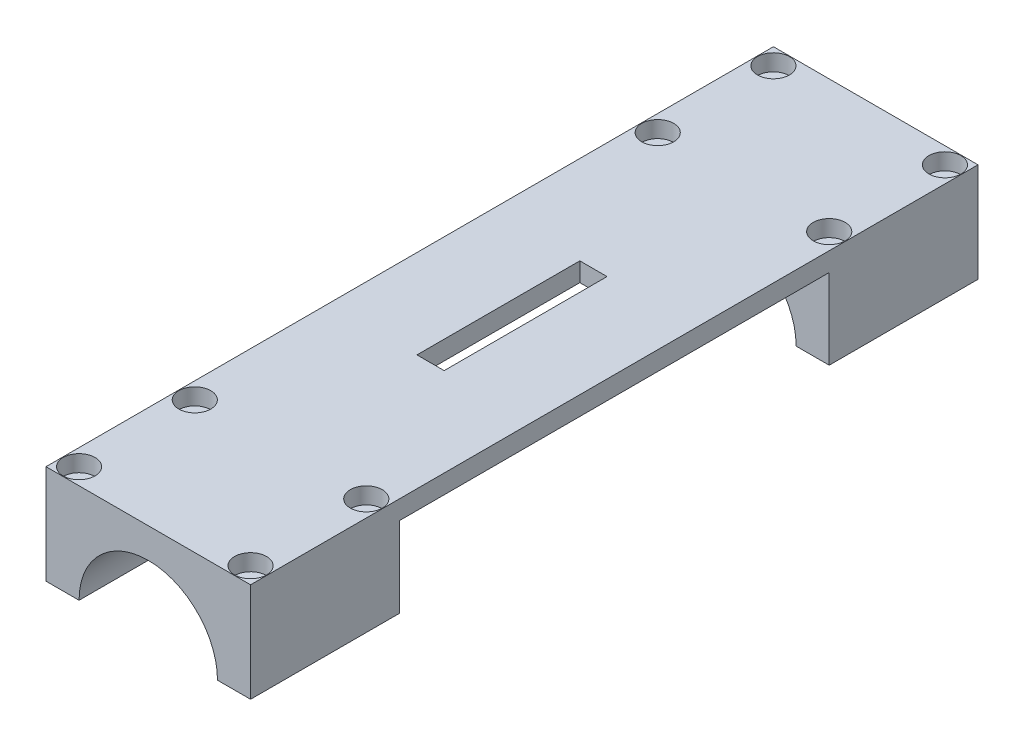
from build123d import *

# Parameters (mm, degrees)
BOSS_EXTRU_1_DEPTH      = 132
ESQUISSE2_W             = 78
ESQUISSE2_H             = 14.57
ENL_V_MAT_EXTRU_1_DEPTH = 132
ESQUISSE3_W             = 4.94012132
ESQUISSE3_H             = 29.556292602
ENL_V_MAT_EXTRU_2_DEPTH = 4
ESQUISSE4_R             = 1.3
ENL_V_MAT_EXTRU_3_DEPTH = 18
ESQUISSE6_R             = 2.9
ENL_V_MAT_EXTRU_5_DEPTH = 3


with BuildPart() as part:
    # Esquisse1 → Boss.-Extru.1 (new body)
    with BuildSketch(Plane.XY):
        with BuildLine():
            Line((-12.560062385, 0), (-18.560062385, 0))
            Line((-18.560062385, 0), (-18.560062385, 18))
            Line((-18.560062385, 18), (18.560062385, 18))
            Line((18.560062385, 18), (18.560062385, 0))
            Line((18.560062385, 0), (12.560062385, 0))
            ThreePointArc((12.560062385, 0), (0, 12.560062385), (-12.560062385, 0))
        make_face()
    extrude(amount=BOSS_EXTRU_1_DEPTH)

    # Esquisse2 → Enlèv. mat.-Extru.1 (cut)
    with BuildSketch(Plane.ZY.offset(18.560062385)):
        with Locations((66, 7.285)):
            Rectangle(ESQUISSE2_W, ESQUISSE2_H)
    extrude(amount=-ENL_V_MAT_EXTRU_1_DEPTH, mode=Mode.SUBTRACT)

    # Esquisse3 → Enlèv. mat.-Extru.2 (cut)
    with BuildSketch(Plane.XZ.offset(-14.57)):
        with Locations((0, 66)):
            Rectangle(ESQUISSE3_W, ESQUISSE3_H)
    extrude(amount=-ENL_V_MAT_EXTRU_2_DEPTH, mode=Mode.SUBTRACT)

    # Esquisse4 → Enlèv. mat.-Extru.3 (cut)
    with BuildSketch(Plane(origin=(0, 18, 0), x_dir=(1, 0, 0), z_dir=(0, 1, 0))):
        with Locations((15.560062385, -3)):
            Circle(ESQUISSE4_R)
        with Locations((15.560062385, -24)):
            Circle(ESQUISSE4_R)
        with Locations((-15.560062385, -3)):
            Circle(ESQUISSE4_R)
        with Locations((-15.560062385, -24)):
            Circle(ESQUISSE4_R)
        with Locations((-15.560062385, -108)):
            Circle(ESQUISSE4_R)
        with Locations((-15.560062385, -129)):
            Circle(ESQUISSE4_R)
        with Locations((15.560062385, -108)):
            Circle(ESQUISSE4_R)
        with Locations((15.560062385, -129)):
            Circle(ESQUISSE4_R)
    extrude(amount=-ENL_V_MAT_EXTRU_3_DEPTH, mode=Mode.SUBTRACT)

    # Esquisse6 → Enlèv. mat.-Extru.5 (cut)
    with BuildSketch(Plane(origin=(0, 18, 0), x_dir=(1, 0, 0), z_dir=(0, 1, 0))):
        with Locations((15.560062385, -3)):
            Circle(ESQUISSE6_R)
        with Locations((15.560062385, -24)):
            Circle(ESQUISSE6_R)
        with Locations((-15.560062385, -3)):
            Circle(ESQUISSE6_R)
        with Locations((-15.560062385, -24)):
            Circle(ESQUISSE6_R)
        with Locations((-15.560062385, -108)):
            Circle(ESQUISSE6_R)
        with Locations((-15.560062385, -129)):
            Circle(ESQUISSE6_R)
        with Locations((15.560062385, -108)):
            Circle(ESQUISSE6_R)
        with Locations((15.560062385, -129)):
            Circle(ESQUISSE6_R)
    extrude(amount=-ENL_V_MAT_EXTRU_5_DEPTH, mode=Mode.SUBTRACT)


solid = part.part
